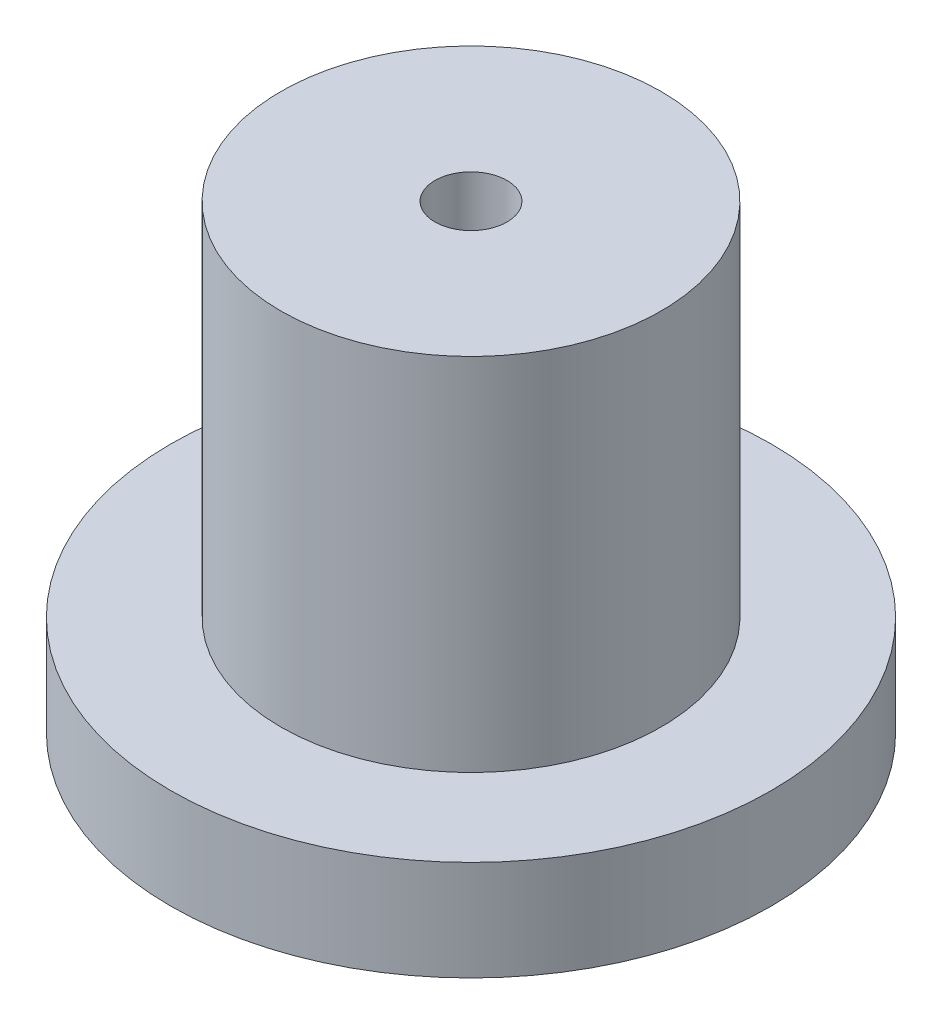
from build123d import *

# Parameters (mm, degrees)
SKETCH2_R            = 15
BOSS_EXTRUDE1_DEPTH  = 5
SKETCH3_R            = 9.5
BOSS_EXTRUDE2_DEPTH  = 18
SKETCH4_R            = 7.5
CUT_EXTRUDE1_DEPTH   = 18
M3_CLEARANCE_HOLE1_D = 3.6


with BuildPart() as part:
    # Sketch2 → Boss-Extrude1 (new body)
    with BuildSketch(Plane(origin=(0, 0, 0), x_dir=(1, 0, 0), z_dir=(0, 1, 0))):
        Circle(SKETCH2_R)
    extrude(amount=BOSS_EXTRUDE1_DEPTH)

    # Sketch3 → Boss-Extrude2 (add)
    with BuildSketch(Plane(origin=(0, 5, 0), x_dir=(1, 0, 0), z_dir=(0, 1, 0))):
        Circle(SKETCH3_R)
    extrude(amount=BOSS_EXTRUDE2_DEPTH)

    # Sketch4 → Cut-Extrude1 (cut)
    with BuildSketch(Plane.XZ):
        Circle(SKETCH4_R)
    extrude(amount=-CUT_EXTRUDE1_DEPTH, mode=Mode.SUBTRACT)

    # M3 Clearance Hole1 (through all)
    with Locations(Plane(origin=(0, 23, 0), x_dir=(1, 0, 0), z_dir=(0, 1, 0))):
        with Locations((0, 0)):
            Hole(M3_CLEARANCE_HOLE1_D / 2)


solid = part.part
